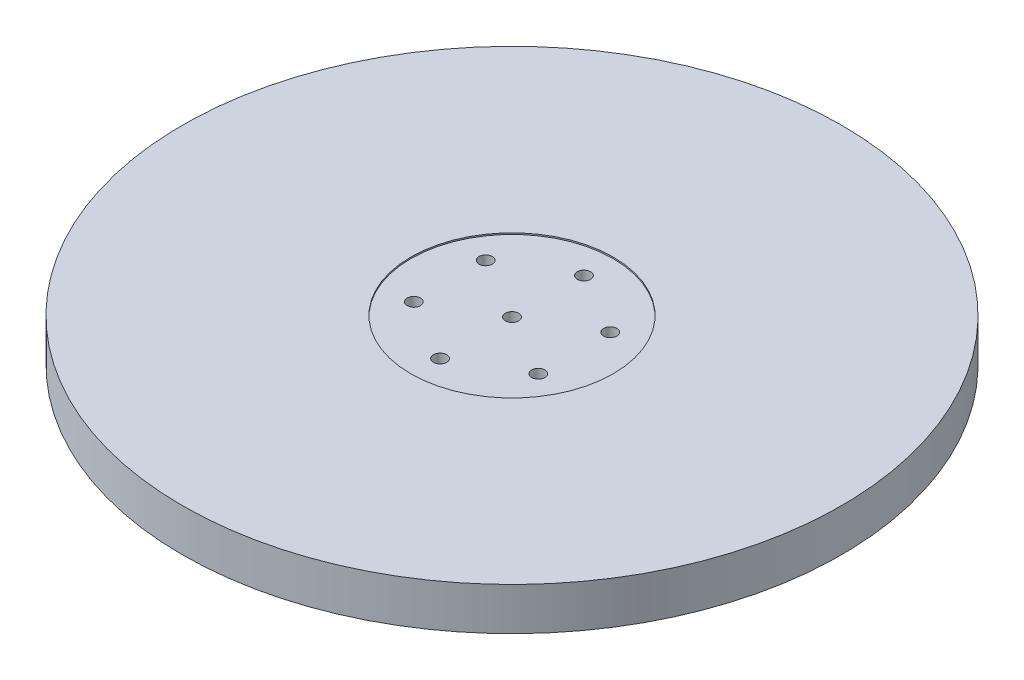
from build123d import *

# Parameters (mm, degrees)
CROQUIS1_R              = 61.885645
SALIENTE_EXTRUIR1_DEPTH = 8
CROQUIS2_R              = 20
CORTAR_EXTRUIR1_DEPTH   = 8
CROQUIS3_R              = 20
SALIENTE_EXTRUIR2_DEPTH = 4
CROQUIS4_R              = 19
SALIENTE_EXTRUIR3_DEPTH = 8.1661
CROQUIS5_R              = 1.25
CORTAR_EXTRUIR2_DEPTH   = 8.1661
CROQUIS6_R              = 1.25
CORTAR_EXTRUIR3_DEPTH   = 8.1661
CROQUIS7_R              = 19
CORTAR_EXTRUIR4_DEPTH   = 4.43


with BuildPart() as part:
    # Croquis1 → Saliente-Extruir1 (new body)
    with BuildSketch(Plane(origin=(0, 0, 0), x_dir=(1, 0, 0), z_dir=(0, 1, 0))):
        Circle(CROQUIS1_R)
    extrude(amount=SALIENTE_EXTRUIR1_DEPTH)

    # Croquis2 → Cortar-Extruir1 (cut)
    with BuildSketch(Plane(origin=(0, 8, 0), x_dir=(1, 0, 0), z_dir=(0, 1, 0))):
        Circle(CROQUIS2_R)
    extrude(amount=-CORTAR_EXTRUIR1_DEPTH, mode=Mode.SUBTRACT)

    # Croquis3 → Saliente-Extruir2 (add)
    with BuildSketch(Plane(origin=(0, 8, 0), x_dir=(1, 0, 0), z_dir=(0, 1, 0))):
        Circle(CROQUIS3_R)
    extrude(amount=-SALIENTE_EXTRUIR2_DEPTH)

    # Croquis4 → Saliente-Extruir3 (add)
    with BuildSketch(Plane(origin=(0, 4, 0), x_dir=(-1, 0, 0), z_dir=(0, -1, 0))):
        Circle(CROQUIS4_R)
    extrude(amount=-SALIENTE_EXTRUIR3_DEPTH)

    # Croquis5 → Cortar-Extruir2 (cut)
    with BuildSketch(Plane(origin=(0, 12.1661, 0), x_dir=(1, 0, 0), z_dir=(0, 1, 0))):
        with Locations((11.691342951, 6.75)):
            Circle(CROQUIS5_R)
        with Locations((0, 13.5)):
            Circle(CROQUIS5_R)
        with Locations((-11.691342951, 6.75)):
            Circle(CROQUIS5_R)
        with Locations((-11.691342951, -6.75)):
            Circle(CROQUIS5_R)
        with Locations((0, -13.5)):
            Circle(CROQUIS5_R)
        with Locations((11.691342951, -6.75)):
            Circle(CROQUIS5_R)
    extrude(amount=-CORTAR_EXTRUIR2_DEPTH, mode=Mode.SUBTRACT)

    # Croquis6 → Cortar-Extruir3 (cut)
    with BuildSketch(Plane(origin=(0, 12.1661, 0), x_dir=(1, 0, 0), z_dir=(0, 1, 0))):
        Circle(CROQUIS6_R)
    extrude(amount=-CORTAR_EXTRUIR3_DEPTH, mode=Mode.SUBTRACT)

    # Croquis7 → Cortar-Extruir4 (cut)
    with BuildSketch(Plane(origin=(0, 12.1661, 0), x_dir=(1, 0, 0), z_dir=(0, 1, 0))):
        Circle(CROQUIS7_R)
    extrude(amount=-CORTAR_EXTRUIR4_DEPTH, mode=Mode.SUBTRACT)


solid = part.part
